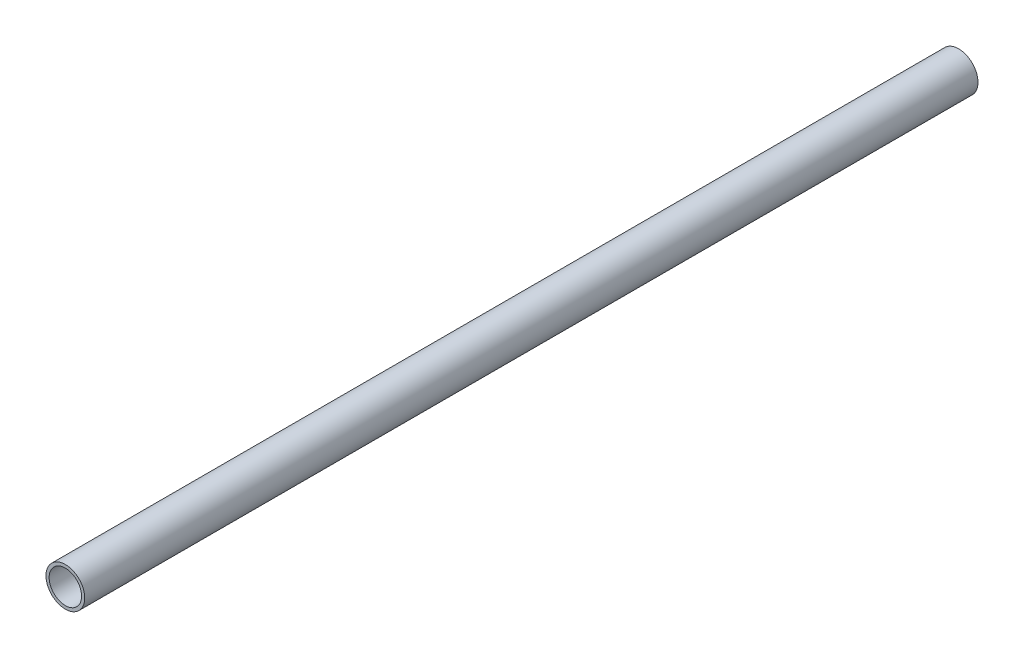
from build123d import *

# Parameters (mm, degrees)
SZKIC1_R                         = 8.35
SZKIC1_R_2                       = 7
DODANIE_WYCI_GNI_CIE1_DEPTH      = 384.125254
DODANIE_WYCI_GNI_CIE1_DEPTH_BACK = 1


with BuildPart() as part:
    # Szkic1 → Dodanie-wyci_gni_cie1 (new body, two sides)
    with BuildSketch(Plane.XY) as dodanie_wyci_gni_cie1_sk:
        Circle(SZKIC1_R)
        Circle(SZKIC1_R_2, mode=Mode.SUBTRACT)
    extrude(amount=DODANIE_WYCI_GNI_CIE1_DEPTH)
    extrude(dodanie_wyci_gni_cie1_sk.sketch, amount=-DODANIE_WYCI_GNI_CIE1_DEPTH_BACK)


solid = part.part
